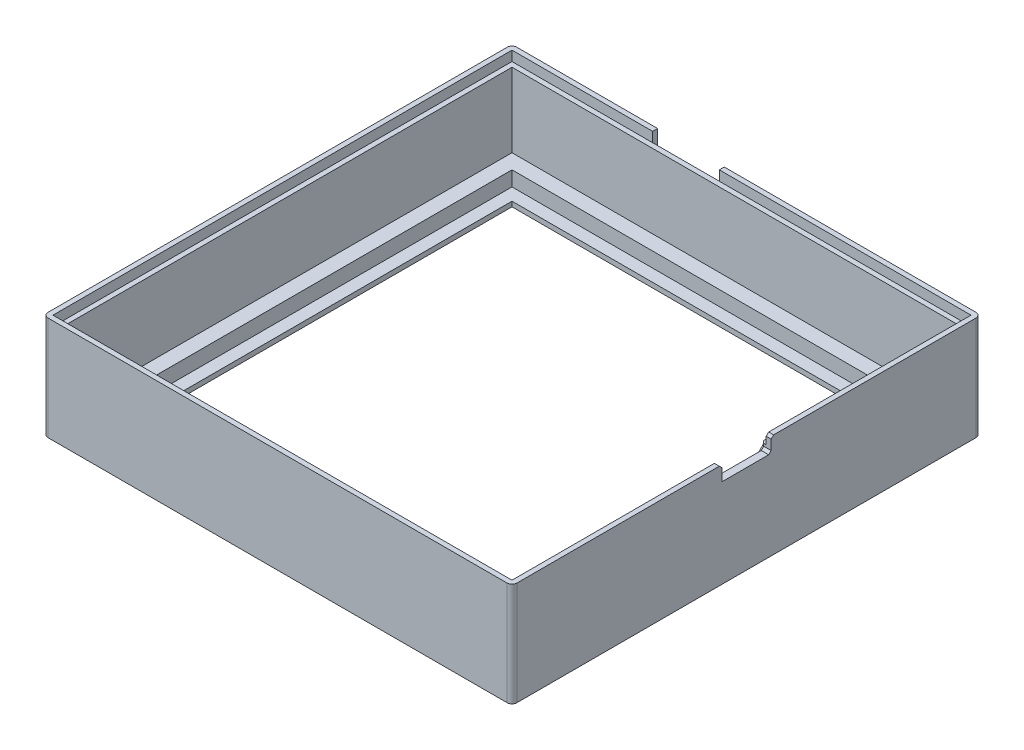
from build123d import *

# Parameters (mm, degrees)
BOSS_EXTRUDE1_DEPTH = 4
SKETCH4_W           = 91
SKETCH4_H           = 91
BOSS_EXTRUDE2_DEPTH = 15
CUT_EXTRUDE3_REACH  = 70.829
SKETCH2_W           = 80
SKETCH2_H           = 80
CUT_EXTRUDE6_REACH  = 109.899
SKETCH7_W           = 10
SKETCH7_H           = 1
SKETCH8_W           = 85
SKETCH8_H           = 85
CUT_EXTRUDE7_DEPTH  = 3
BOSS_EXTRUDE3_DEPTH = 2
CHAMFER1_SIZE       = 0.5
CUT_EXTRUDE8_REACH  = 110.269
SKETCH11_W          = 9.5
SKETCH11_H          = 1
CUT_EXTRUDE10_DEPTH = 1


with BuildPart() as part:
    # Sketch1 → Boss-Extrude1 (new body)
    with BuildSketch(Plane(origin=(0, 0, 0), x_dir=(1, 0, 0), z_dir=(0, 1, 0))):
        with BuildLine():
            Line((-46.5, -47.5), (46.5, -47.5))
            ThreePointArc((46.5, -47.5), (47.207106781, -47.207106781), (47.5, -46.5))
            Line((47.5, -46.5), (47.5, 46.5))
            ThreePointArc((47.5, 46.5), (47.207106781, 47.207106781), (46.5, 47.5))
            Line((46.5, 47.5), (-46.5, 47.5))
            ThreePointArc((-46.5, 47.5), (-47.207106781, 47.207106781), (-47.5, 46.5))
            Line((-47.5, 46.5), (-47.5, -46.5))
            ThreePointArc((-47.5, -46.5), (-47.207106781, -47.207106781), (-46.5, -47.5))
        make_face()
    extrude(amount=BOSS_EXTRUDE1_DEPTH)

    # Sketch4 → Boss-Extrude2 (add)
    with BuildSketch(Plane(origin=(0, 4, 0), x_dir=(1, 0, 0), z_dir=(0, 1, 0))):
        with BuildLine():
            Line((47.5, -46.5), (47.5, 46.5))
            ThreePointArc((47.5, 46.5), (47.207106781, 47.207106781), (46.5, 47.5))
            Line((46.5, 47.5), (-46.5, 47.5))
            ThreePointArc((-46.5, 47.5), (-47.207106781, 47.207106781), (-47.5, 46.5))
            Line((-47.5, 46.5), (-47.5, -46.5))
            ThreePointArc((-47.5, -46.5), (-47.207106781, -47.207106781), (-46.5, -47.5))
            Line((-46.5, -47.5), (46.5, -47.5))
            ThreePointArc((46.5, -47.5), (47.207106781, -47.207106781), (47.5, -46.5))
        make_face()
        Rectangle(SKETCH4_W, SKETCH4_H, mode=Mode.SUBTRACT)
    extrude(amount=BOSS_EXTRUDE2_DEPTH)

    # Sketch2 → Cut-Extrude3 (cut, up to next)
    with BuildSketch(Plane(origin=(0, 4, 0), x_dir=(1, 0, 0), z_dir=(0, 1, 0)), mode=Mode.PRIVATE) as cut_extrude3_sk1:
        Rectangle(SKETCH2_W, SKETCH2_H)
    cut_extrude3_tool1 = extrude(cut_extrude3_sk1.sketch, amount=-CUT_EXTRUDE3_REACH, mode=Mode.PRIVATE) & part.part
    add(cut_extrude3_tool1.solids().sort_by_distance((0, 4, 0))[0], mode=Mode.SUBTRACT)

    # Sketch7 → Cut-Extrude6 (cut, up to next)
    with BuildSketch(Plane(origin=(47.5, 0, 0), x_dir=(0, 0, -1), z_dir=(1, 0, 0)), mode=Mode.PRIVATE) as cut_extrude6_sk1:
        with Locations((0, 18.5)):
            Rectangle(SKETCH7_W, SKETCH7_H)
    cut_extrude6_tool1 = extrude(cut_extrude6_sk1.sketch, amount=-CUT_EXTRUDE6_REACH, mode=Mode.PRIVATE) & part.part
    add(cut_extrude6_tool1.solids().sort_by_distance((47.5, 18.5, 0))[0], mode=Mode.SUBTRACT)

    # Sketch8 → Cut-Extrude7 (cut)
    with BuildSketch(Plane(origin=(0, 4, 0), x_dir=(1, 0, 0), z_dir=(0, 1, 0))):
        Rectangle(SKETCH8_W, SKETCH8_H)
    extrude(amount=-CUT_EXTRUDE7_DEPTH, mode=Mode.SUBTRACT)

    # Sketch10 → Boss-Extrude3 (add)
    with BuildSketch(Plane(origin=(0, 19, 0), x_dir=(1, 0, 0), z_dir=(0, 1, 0))):
        with BuildLine():
            Line((46.5, 5), (46.5, 46.5))
            Line((46.5, 46.5), (-46.5, 46.5))
            Line((-46.5, 46.5), (-46.5, -46.5))
            Line((-46.5, -46.5), (46.5, -46.5))
            Line((46.5, -46.5), (46.5, -5))
            Line((46.5, -5), (47.5, -5))
            Line((47.5, -5), (47.5, -46.5))
            ThreePointArc((47.5, -46.5), (47.207106781, -47.207106781), (46.5, -47.5))
            Line((46.5, -47.5), (-46.5, -47.5))
            ThreePointArc((-46.5, -47.5), (-47.207106781, -47.207106781), (-47.5, -46.5))
            Line((-47.5, -46.5), (-47.5, 46.5))
            ThreePointArc((-47.5, 46.5), (-47.207106781, 47.207106781), (-46.5, 47.5))
            Line((-46.5, 47.5), (46.5, 47.5))
            ThreePointArc((46.5, 47.5), (47.207106781, 47.207106781), (47.5, 46.5))
            Line((47.5, 46.5), (47.5, 5))
            Line((47.5, 5), (46.5, 5))
        make_face()
    extrude(amount=BOSS_EXTRUDE3_DEPTH)

    # Chamfer1
    chamfer1_edges = [part.edges().sort_by_distance(p)[0] for p in [
        (47, 21, 5),
        (47, 21, -5),
        (45.5, 18.5, -5),
        (45.5, 18, 0),
        (46.5, 18, -5),
        (46, 19, 5),
    ]]
    chamfer(chamfer1_edges, length=CHAMFER1_SIZE)

    # Sketch11 → Cut-Extrude8 (cut, up to next)
    with BuildSketch(Plane(origin=(0, 0, -47.5), x_dir=(-1, 0, 0), z_dir=(0, 0, -1)), mode=Mode.PRIVATE) as cut_extrude8_sk1:
        with Locations((11.25, 20.5)):
            Rectangle(SKETCH11_W, SKETCH11_H)
    cut_extrude8_tool1 = extrude(cut_extrude8_sk1.sketch, amount=-CUT_EXTRUDE8_REACH, mode=Mode.PRIVATE) & part.part
    add(cut_extrude8_tool1.solids().sort_by_distance((-11.25, 20.5, -47.5))[0], mode=Mode.SUBTRACT)

    # Sketch12 → Cut-Extrude10 (cut)
    with BuildSketch(Plane(origin=(0, 0, -47.5), x_dir=(-1, 0, 0), z_dir=(0, 0, -1))):
        Polygon((16, 20), (16, 21), (18, 21), (18, 18), (4.5, 18), (4.5, 21), (6.5, 21), (6.5, 20), align=None)
    extrude(amount=-CUT_EXTRUDE10_DEPTH, mode=Mode.SUBTRACT)


solid = part.part
